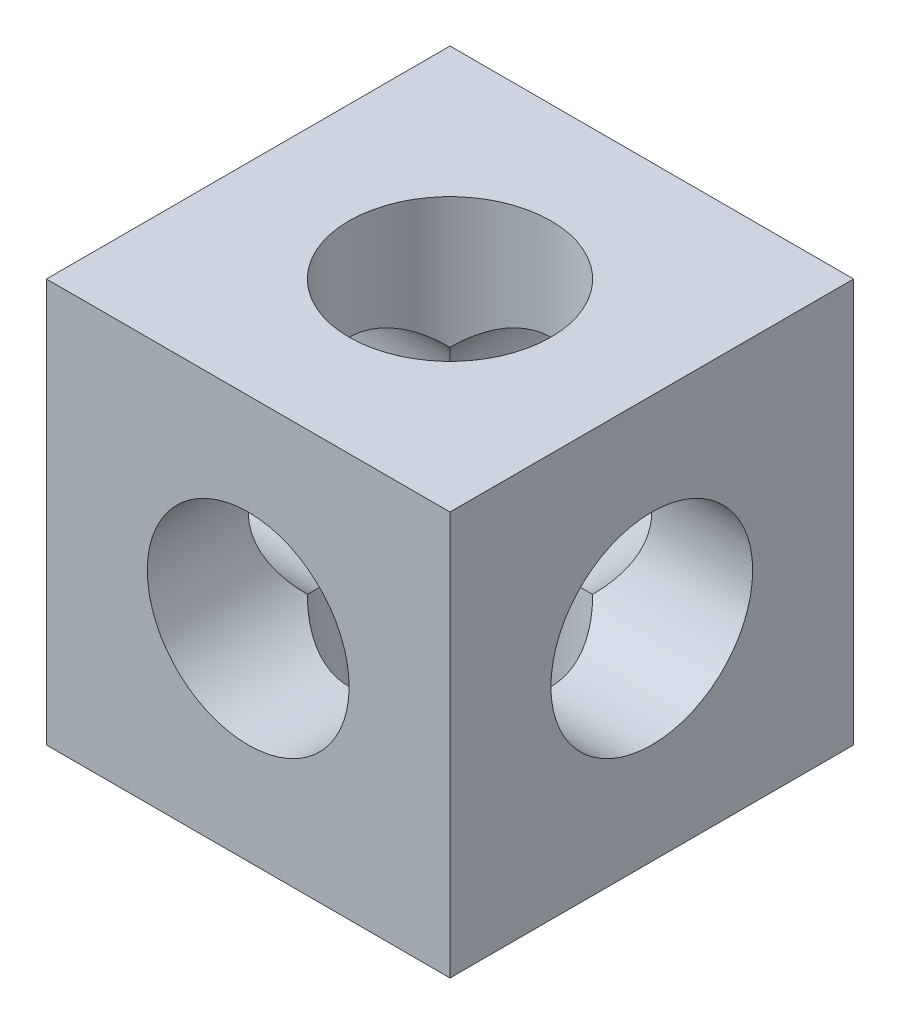
from build123d import *

# Parameters (mm, degrees)
SKETCH1_W           = 50.8
SKETCH1_H           = 50.8
BOSS_EXTRUDE1_DEPTH = 50.8
SKETCH2_R           = 12.7
CUT_EXTRUDE1_DEPTH  = 50.8
SKETCH3_R           = 12.7
CUT_EXTRUDE2_DEPTH  = 50.8
SKETCH4_R           = 12.7
CUT_EXTRUDE3_DEPTH  = 50.8


with BuildPart() as part:
    # Sketch1 → Boss-Extrude1 (new body)
    with BuildSketch(Plane.XY):
        with Locations((25.4, 25.4)):
            Rectangle(SKETCH1_W, SKETCH1_H)
    extrude(amount=BOSS_EXTRUDE1_DEPTH)

    # Sketch2 → Cut-Extrude1 (cut)
    with BuildSketch(Plane.XY.offset(50.8)):
        with Locations((25.4, 25.4)):
            Circle(SKETCH2_R)
    extrude(amount=-CUT_EXTRUDE1_DEPTH, mode=Mode.SUBTRACT)

    # Sketch3 → Cut-Extrude2 (cut)
    with BuildSketch(Plane(origin=(0, 50.8, 0), x_dir=(1, 0, 0), z_dir=(0, 1, 0))):
        with Locations((25.4, -25.4)):
            Circle(SKETCH3_R)
    extrude(amount=-CUT_EXTRUDE2_DEPTH, mode=Mode.SUBTRACT)

    # Sketch4 → Cut-Extrude3 (cut)
    with BuildSketch(Plane.ZY):
        with Locations((25.4, 25.4)):
            Circle(SKETCH4_R)
    extrude(amount=-CUT_EXTRUDE3_DEPTH, mode=Mode.SUBTRACT)


solid = part.part
